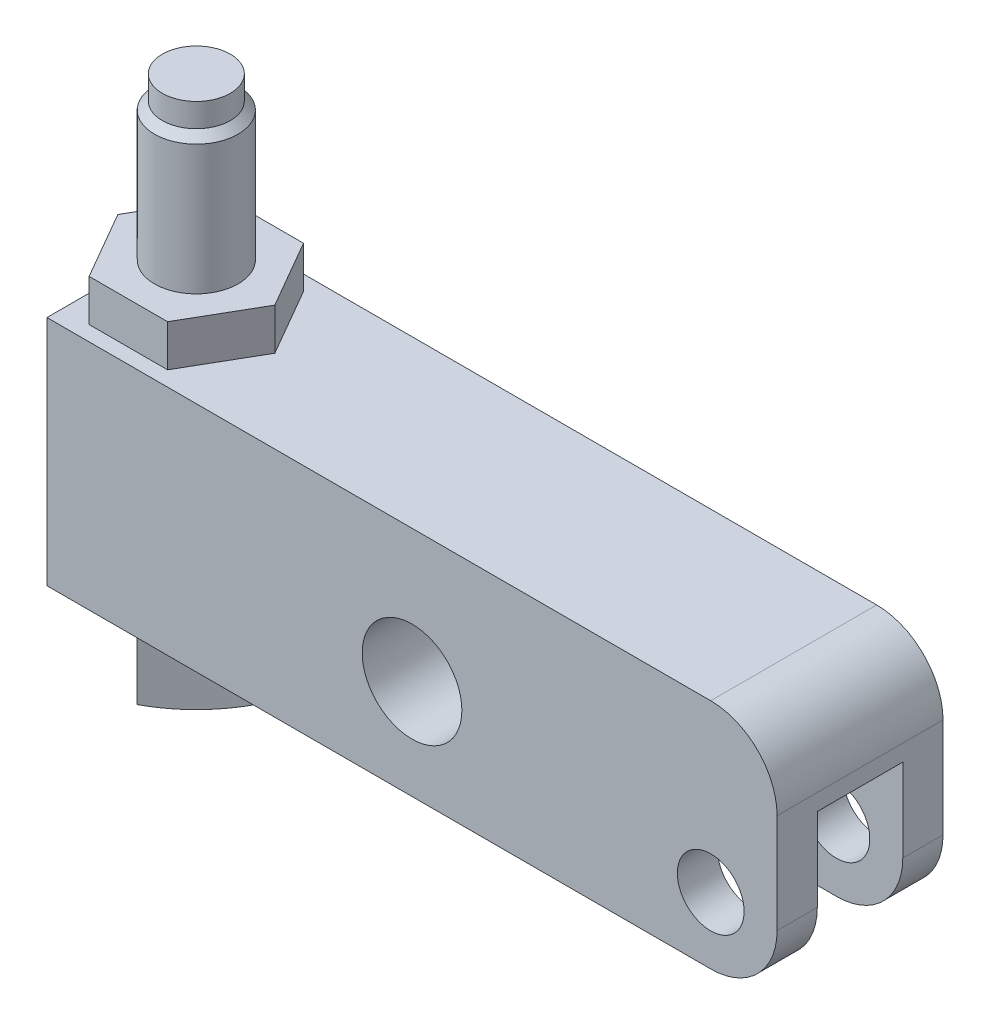
from build123d import *

# Parameters (mm, degrees)
SKETCH11_W         = 69.85
SKETCH11_H         = 22.225
SKETCH11_R         = 3.19405
SKETCH11_R_2       = 4.76885
EXTRUDE3_DEPTH     = 7.9375
CUT_EXTRUDE1_DEPTH = 14.3002
FILLET1_R          = 6.35
EXTRUDE4_DEPTH     = 3.9878
SKETCH15_R         = 15.311270849
CUT_EXTRUDE2_DEPTH = 9.001


with BuildPart() as part:
    # Sketch11 → Extrude3 (new body, symmetric)
    with BuildSketch(Plane.XY):
        with Locations((-28.575, 4.7625)):
            Rectangle(SKETCH11_W, SKETCH11_H)
        Circle(SKETCH11_R, mode=Mode.SUBTRACT)
        with Locations((-28.575, 3.175)):
            Circle(SKETCH11_R_2, mode=Mode.SUBTRACT)
    extrude(amount=EXTRUDE3_DEPTH, both=True)

    # Sketch12 → Cut-Extrude1 (cut)
    with BuildSketch(Plane.XZ.offset(6.35)):
        with BuildLine():
            Line((-7.9248, 4.0894), (6.35, 4.0894))
            Line((6.35, 4.0894), (6.35, -4.0894))
            Line((6.35, -4.0894), (-7.9248, -4.0894))
            ThreePointArc((-7.9248, -4.0894), (-12.0142, 0), (-7.9248, 4.0894))
        make_face()
    extrude(amount=-CUT_EXTRUDE1_DEPTH, mode=Mode.SUBTRACT)

    # Fillet1
    fillet1_edges = [part.edges().sort_by_distance(p)[0] for p in [
        (6.35, -6.35, -6.01345),
        (6.35, 15.875, 0),
        (6.35, -6.35, 6.01345),
    ]]
    fillet(fillet1_edges, radius=FILLET1_R)

    # Sketch13 → Extrude4 (add)
    with BuildSketch(Plane(origin=(0, 15.875, 0), x_dir=(1, 0, 0), z_dir=(0, 1, 0))):
        Polygon((-49.641675219, 0), (-53.39583761, 6.5024), (-60.90416239, 6.5024), (-64.658324781, 0), (-60.90416239, -6.5024), (-53.39583761, -6.5024), align=None)
    extrude(amount=EXTRUDE4_DEPTH)

    # Sketch14 → Revolve2 (revolve)
    with BuildSketch(Plane.XY):
        with BuildLine():
            Line((-60.4012, 33.02), (-60.4012, 35.2806))
            Line((-60.4012, 35.2806), (-57.15, 35.2806))
            Line((-57.15, 35.2806), (-57.15, -14.986))
            ThreePointArc((-57.15, -14.986), (-65.618148204, -13.085052733), (-72.461270849, -7.747))
            Line((-72.461270849, -7.747), (-72.461270849, -6.985))
            Line((-72.461270849, -6.985), (-61.1505, -6.985))
            Line((-61.1505, -6.985), (-61.1505, 32.2707))
            Line((-61.1505, 32.2707), (-60.4012, 33.02))
        make_face()
    revolve(axis=Axis((-57.15, 48.481677569, 0), (0, -1, 0)))

    # Sketch15 → Cut-Extrude2 (cut, through all)
    with BuildSketch(Plane(origin=(0, -6.985, 0), x_dir=(1, 0, 0), z_dir=(0, 1, 0))):
        with Locations((-57.15, 0)):
            Circle(SKETCH15_R)
        Polygon((-57.15, 5.657561356), (-62.807561356, 0), (-57.15, -5.657561356), (-51.492438644, 0), align=None, mode=Mode.SUBTRACT)
    extrude(amount=-CUT_EXTRUDE2_DEPTH, mode=Mode.SUBTRACT)


solid = part.part
